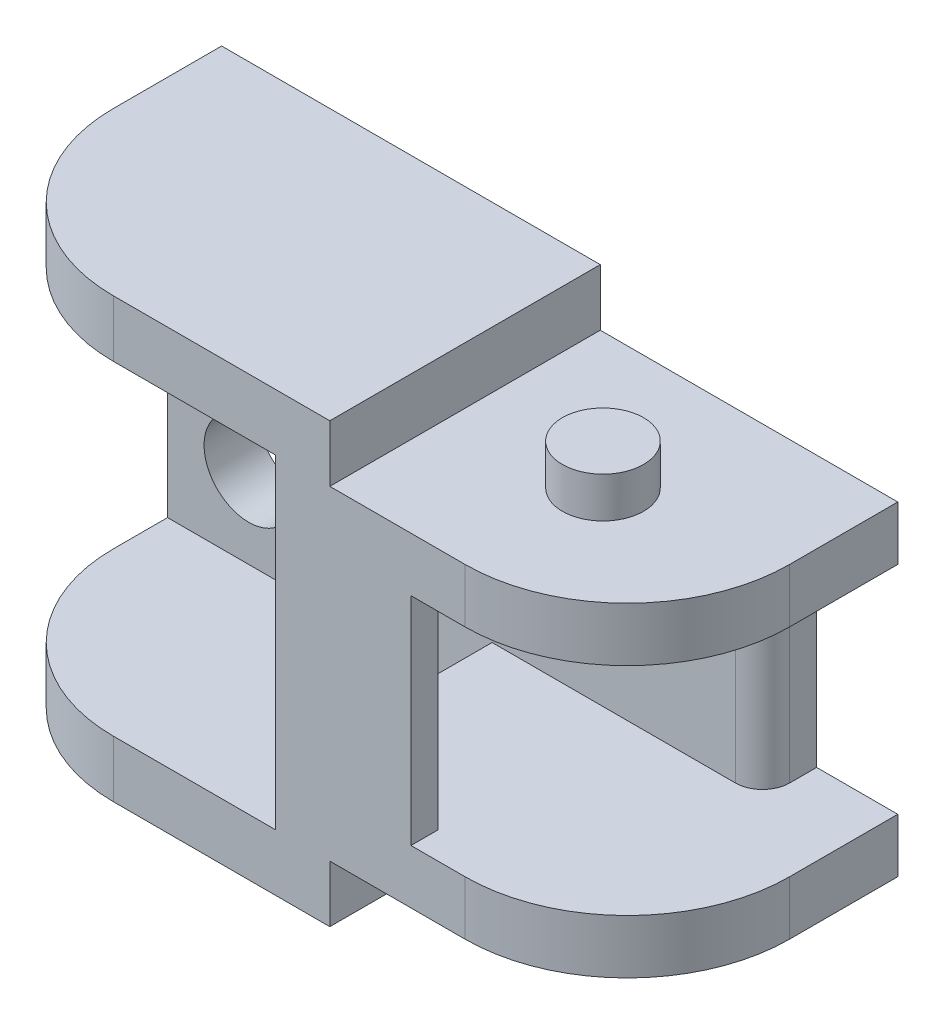
from build123d import *

# Parameters (mm, degrees)
EXTRUDE_2_DEPTH     = 10
SKETCH_3_R          = 1.5
EXTRUDE_3_DEPTH     = 1.5
SKETCH_5_R          = 1.65
CUT_EXTRUDE_2_DEPTH = 27.084669827
FILLET_1_R          = 6
SKETCH_6_W          = 10
SKETCH_6_H          = 1
SKETCH_6_W_2        = 5
EXTRUDE_4_DEPTH     = 4
SKETCH_7_W          = 5.689599517
SKETCH_7_H          = 3.3
CUT_EXTRUDE_3_DEPTH = 0.5
SKETCH_8_W          = 11.306526487
SKETCH_8_H          = 19.042570926
CUT_EXTRUDE_4_DEPTH = 30.624989451
MOVE_FACE_1_BY      = 12
CUT_EXTRUDE_5_REACH = 31.625
SKETCH_9_W          = 14.188350819
SKETCH_9_H          = 12
SKETCH_10_R         = 1.65
CUT_EXTRUDE_6_DEPTH = 30.302559615
FILLET_2_R          = 6
MOVE_FACE_2_BY      = 1
FILLET_3_R          = 1


with BuildPart() as part:
    # Эскиз2 → Бобышка-Вытянуть2 (new body)
    with BuildSketch(Plane.XY):
        Polygon((0, 0), (0, 2), (13, 2), (13, -0.1), (24, -0.1), (24, -2.1), (11, -2.1), (11, 0), align=None)
    extrude(amount=EXTRUDE_2_DEPTH)

    # Эскиз3 → Бобышка-Вытянуть3 (add)
    with BuildSketch(Plane(origin=(0, -0.1, 0), x_dir=(1, 0, 0), z_dir=(0, 1, 0))):
        with Locations(Location((18.1, -5, 0), (0, 0, 90))):
            Circle(SKETCH_3_R)
    extrude(amount=EXTRUDE_3_DEPTH)

    # Эскиз5 → Вырез-Вытянуть2 (cut, through all)
    with BuildSketch(Plane.XZ):
        with Locations((5, 5)):
            Circle(SKETCH_5_R)
    extrude(amount=-CUT_EXTRUDE_2_DEPTH, mode=Mode.SUBTRACT)

    # Скругление1
    fillet_1_edges = [part.edges().sort_by_distance(p)[0] for p in [
        (24, -1.1, 10),
        (0, 1, 10),
    ]]
    fillet(fillet_1_edges, radius=FILLET_1_R)

    # Эскиз6 → Бобышка-Вытянуть4 (add)
    with BuildSketch(Plane(origin=(0, -2.1, 0), x_dir=(-1, 0, 0), z_dir=(0, -1, 0))):
        with Locations((-16, -0.5)):
            Rectangle(SKETCH_6_W, SKETCH_6_H)
        with Locations((-13.5, -9.5)):
            Rectangle(SKETCH_6_W_2, SKETCH_6_H)
    extrude(amount=EXTRUDE_4_DEPTH)

    # Эскиз7 → Вырез-Вытянуть3 (cut)
    with BuildSketch(Plane.XZ):
        with Locations((2.155200242, 5)):
            Rectangle(SKETCH_7_W, SKETCH_7_H)
    extrude(amount=-CUT_EXTRUDE_3_DEPTH, mode=Mode.SUBTRACT)

    # Зеркальное отражение1: part across plane


with BuildPart() as part_1:
    add(part.part)
    add(part.part.mirror(Plane.ZX.offset(-6.1)))

    # Эскиз8 → Вырез-Вытянуть4 (cut, through all)
    with BuildSketch(Plane.XY.offset(10)):
        with Locations((5.346736757, -6.608790605)):
            Rectangle(SKETCH_8_W, SKETCH_8_H)
    extrude(amount=-CUT_EXTRUDE_4_DEPTH, mode=Mode.SUBTRACT)

    # Move Face 1: a face moved outward by 12.0
    extrude(part_1.faces().sort_by_distance((11, -10.15, 5))[0], amount=MOVE_FACE_1_BY, dir=(-1, 0, 0))

    # Вырез-Вытянуть5: up to this face of the body (flat: up to its plane)
    cut_extrude_5_end = Plane(part_1.part.faces().sort_by_distance((10, -6.1, 1))[0])
    # Эскиз9 → Вырез-Вытянуть5 (cut, up to the picked face)
    with BuildSketch(Plane.XY.offset(10), mode=Mode.PRIVATE) as cut_extrude_5_sk1:
        with Locations((3.90582459, -6.1)):
            Rectangle(SKETCH_9_W, SKETCH_9_H)
    cut_extrude_5_tool1 = split(extrude(cut_extrude_5_sk1.sketch, amount=-CUT_EXTRUDE_5_REACH, mode=Mode.PRIVATE), bisect_by=cut_extrude_5_end, keep=Keep.BOTH, mode=Mode.PRIVATE)
    add(cut_extrude_5_tool1.solids().sort_by(Axis((3.905825, -6.1, 10), (0, 0, -1)))[0], mode=Mode.SUBTRACT)

    # Эскиз10 → Вырез-Вытянуть6 (cut, through all)
    with BuildSketch(Plane.XY.offset(1)):
        with Locations((2, -9.1)):
            Circle(SKETCH_10_R)
        with Locations((8, -3.1)):
            Circle(SKETCH_10_R)
    extrude(amount=-CUT_EXTRUDE_6_DEPTH, mode=Mode.SUBTRACT)

    # Скругление2
    fillet_2_edges = [part_1.edges().sort_by_distance(p)[0] for p in [
        (-1, -13.15, 10),
        (-1, 0.95, 10),
    ]]
    fillet(fillet_2_edges, radius=FILLET_2_R)

    # Move Face 2: a face moved outward by 1.0
    extrude(part_1.faces().sort_by_distance((9.253385216, -6.1, 1))[0], amount=MOVE_FACE_2_BY, dir=(0, 0, 1))

    # Скругление3
    fillet_3_edges = [part_1.edges().sort_by_distance(p)[0] for p in [
        (21, -6.1, 2),
    ]]
    fillet(fillet_3_edges, radius=FILLET_3_R)


solid = part_1.part
